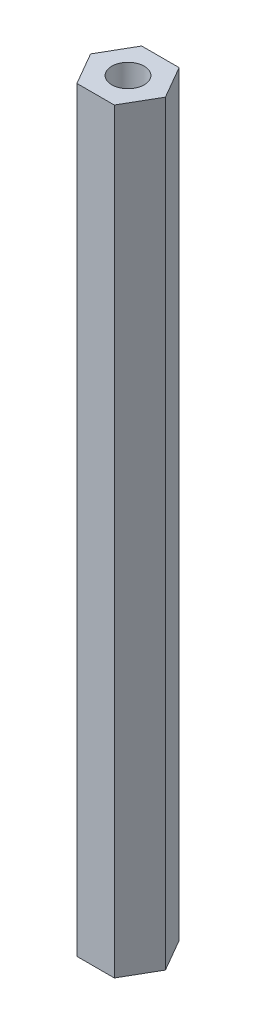
from build123d import *

# Parameters (mm, degrees)
SKETCH_1_R      = 1.5
EXTRUDE_1_DEPTH = 70


with BuildPart() as part:
    # 草图1 → 凸台-拉伸1 (new body)
    with BuildSketch(Plane(origin=(0, 0, 0), x_dir=(1, 0, 0), z_dir=(0, 1, 0))):
        Polygon((3.464101615, 0), (1.732050808, 3), (-1.732050808, 3), (-3.464101615, 0), (-1.732050808, -3), (1.732050808, -3), align=None)
        Circle(SKETCH_1_R, mode=Mode.SUBTRACT)
    extrude(amount=EXTRUDE_1_DEPTH)


solid = part.part
